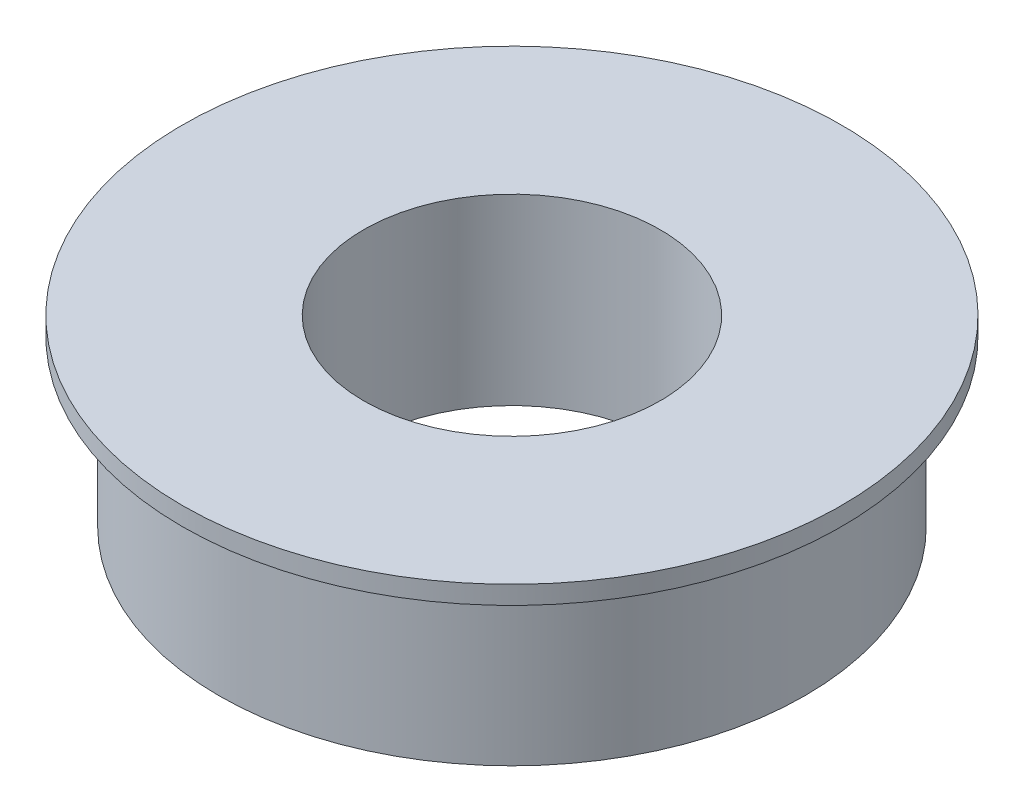
from build123d import *

# Parameters (mm, degrees)
SKETCH1_R           = 8
BOSS_EXTRUDE1_DEPTH = 4.5
SKETCH2_R           = 9
BOSS_EXTRUDE2_DEPTH = 0.5
SKETCH3_R           = 4.05
CUT_EXTRUDE1_DEPTH  = 6


with BuildPart() as part:
    # Sketch1 → Boss-Extrude1 (new body)
    with BuildSketch(Plane(origin=(0, 0, 0), x_dir=(1, 0, 0), z_dir=(0, 1, 0))):
        Circle(SKETCH1_R)
    extrude(amount=BOSS_EXTRUDE1_DEPTH)

    # Sketch2 → Boss-Extrude2 (add)
    with BuildSketch(Plane(origin=(0, 4.5, 0), x_dir=(1, 0, 0), z_dir=(0, 1, 0))):
        Circle(SKETCH2_R)
    extrude(amount=BOSS_EXTRUDE2_DEPTH)

    # Sketch3 → Cut-Extrude1 (cut, through all)
    with BuildSketch(Plane(origin=(0, 5, 0), x_dir=(1, 0, 0), z_dir=(0, 1, 0))):
        Circle(SKETCH3_R)
    extrude(amount=-CUT_EXTRUDE1_DEPTH, mode=Mode.SUBTRACT)


solid = part.part
